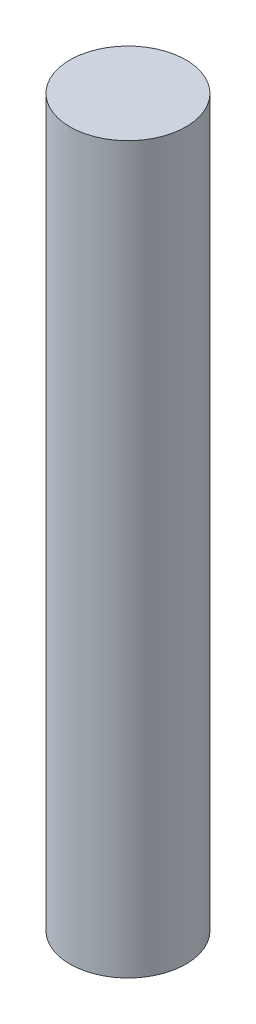
from build123d import *

# Parameters (mm, degrees)
CROQUIS1_R              = 4
SALIENTE_EXTRUIR1_DEPTH = 50


with BuildPart() as part:
    # Croquis1 → Saliente-Extruir1 (new body)
    with BuildSketch(Plane(origin=(0, 0, 0), x_dir=(1, 0, 0), z_dir=(0, 1, 0))):
        Circle(CROQUIS1_R)
    extrude(amount=SALIENTE_EXTRUIR1_DEPTH)


solid = part.part
